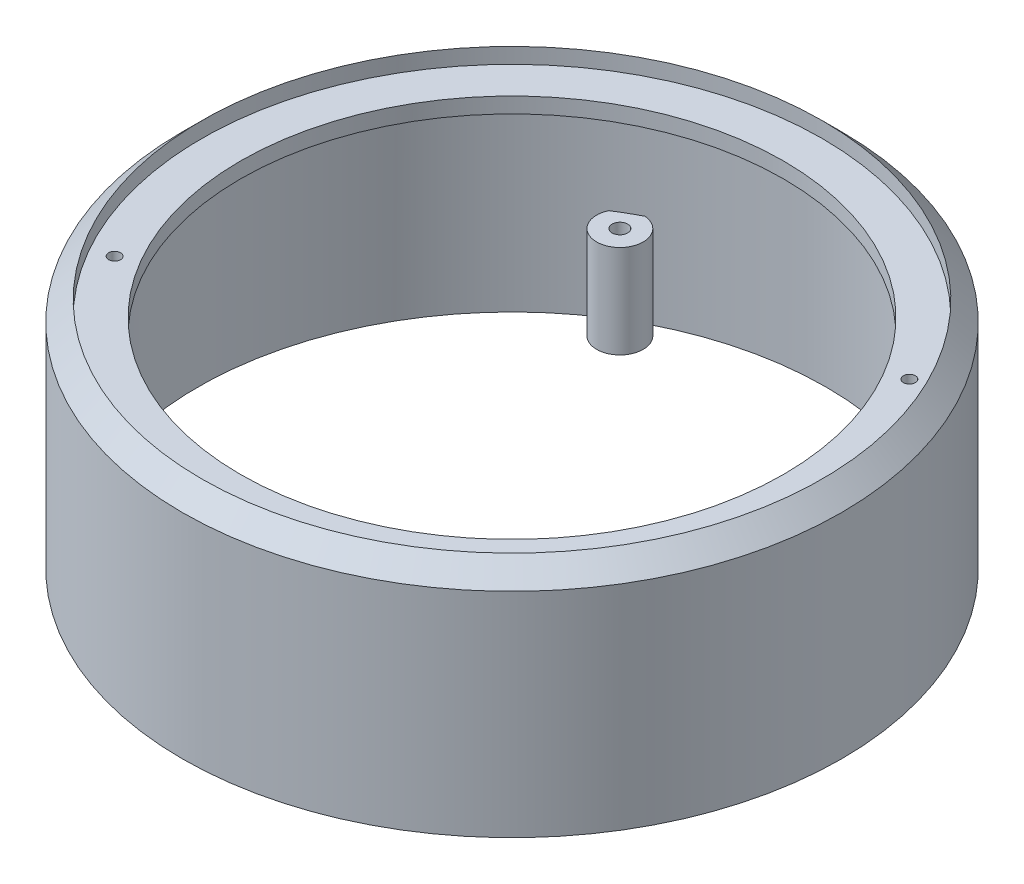
from build123d import *

# Parameters (mm, degrees)
SKETCH2_R           = 2
BOSS_EXTRUDE1_DEPTH = 24
SKETCH3_R           = 1.55
CUT_EXTRUDE1_DEPTH  = 10


with BuildPart() as part:
    # Sketch1 → Revolve1 (revolve)
    with BuildSketch(Plane.XY):
        Polygon((-85, 0), (-85, 55), (-80, 60), (-80, 56), (-70, 56), (-70, 52), (-81, 52), (-81, 0), align=None)
    revolve(axis=Axis((0, -62.463486945, 0), (0, 1, 0)))

    # Sketch2 → Boss-Extrude1 (add)
    with BuildSketch(Plane.XZ):
        with BuildLine():
            ThreePointArc((-43.428412772, 68.37377395), (-35, 60.621778265), (-37.499218807, 71.796995681))
            ThreePointArc((-37.499218807, 71.796995681), (-40.5, 70.148057707), (-43.428412772, 68.37377395))
        make_face()
        with Locations((-38, 65.817930688)):
            Circle(SKETCH2_R, mode=Mode.SUBTRACT)
        with BuildLine():
            ThreePointArc((-43.428412772, -68.37377395), (-40.5, -70.148057707), (-37.499218807, -71.796995681))
            ThreePointArc((-37.499218807, -71.796995681), (-35, -60.621778265), (-43.428412772, -68.37377395))
        make_face()
        with Locations((-38, -65.817930688)):
            Circle(SKETCH2_R, mode=Mode.SUBTRACT)
        with BuildLine():
            ThreePointArc((81, 0), (80.981905874, 1.711993298), (80.927631579, 3.423221731))
            ThreePointArc((80.927631579, 3.423221731), (70, 0), (80.927631579, -3.423221731))
            ThreePointArc((80.927631579, -3.423221731), (80.981905874, -1.711993298), (81, 0))
        make_face()
        with Locations((76, 0)):
            Circle(SKETCH2_R, mode=Mode.SUBTRACT)
    extrude(amount=-BOSS_EXTRUDE1_DEPTH)

    # Sketch3 → Cut-Extrude1 (cut)
    with BuildSketch(Plane(origin=(0, 56, 0), x_dir=(1, 0, 0), z_dir=(0, 1, 0))):
        with Locations((-64.951905284, -37.5)):
            Circle(SKETCH3_R)
        with Locations((64.951905284, 37.5)):
            Circle(SKETCH3_R)
    extrude(amount=-CUT_EXTRUDE1_DEPTH, mode=Mode.SUBTRACT)


solid = part.part
